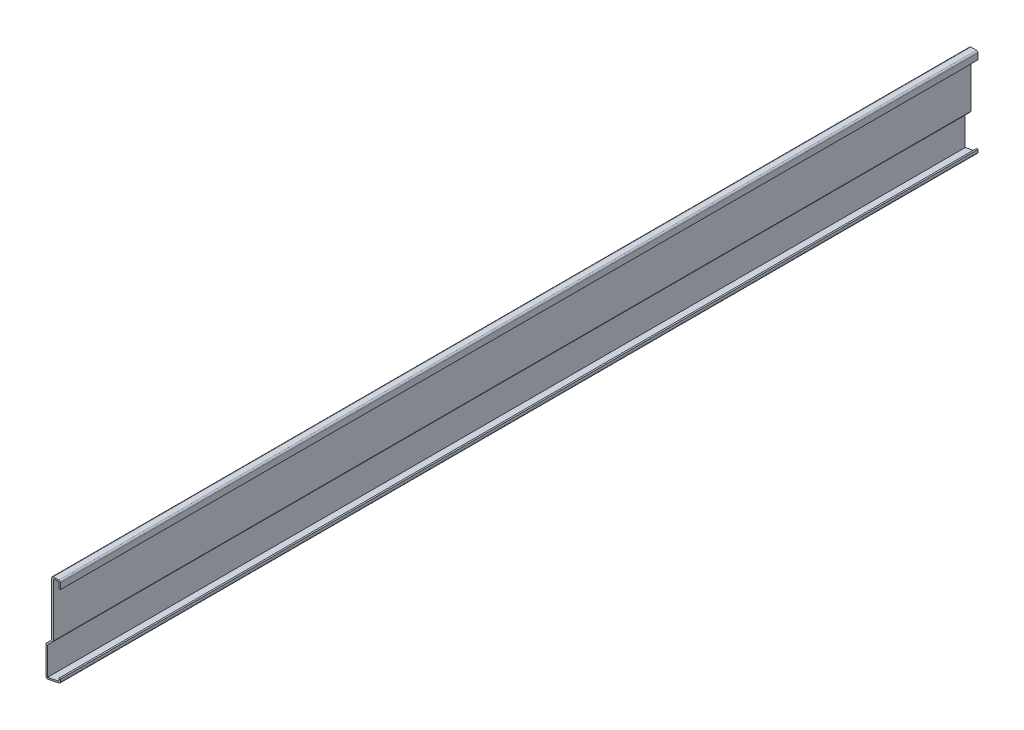
from build123d import *

# Parameters (mm, degrees)
EXTRUDE_THIN1_DEPTH = 762
FILLET1_R           = 1.27


with BuildPart() as part:
    # Sketch1 → Extrude-Thin1 (new body)
    with BuildSketch(Plane.XY):
        Polygon((0, 69.85), (0, 76.2), (-7.14375, 76.2), (-7.14375, 30.1625), (-11.90625, 25.4), (-11.90625, 0), (0, 2.38125), (0, 5.55625), (-1.27, 5.55625), (-1.27, 3.422400956), (-10.63625, 1.549150956), (-10.63625, 24.873948776), (-5.87375, 29.636448776), (-5.87375, 74.93), (-1.27, 74.93), (-1.27, 69.85), align=None)
    extrude(amount=-EXTRUDE_THIN1_DEPTH)

    # Fillet1
    fillet1_edges = [part.edges().sort_by_distance(p)[0] for p in [
        (0, 2.38125, -381),
        (-11.90625, 0, -381),
        (-11.90625, 25.4, -381),
        (-7.14375, 76.2, -381),
        (0, 76.2, -381),
        (-5.87375, 29.636448776, -381),
    ]]
    fillet(fillet1_edges, radius=FILLET1_R)


solid = part.part
